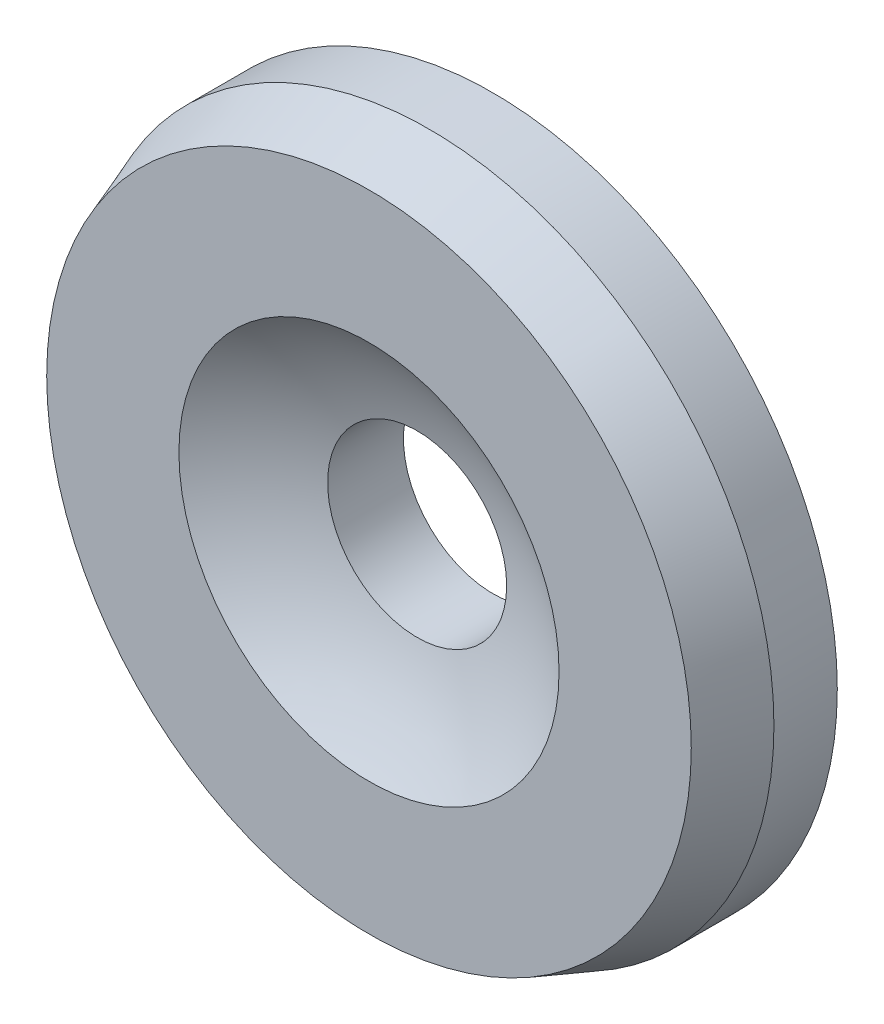
from build123d import *


with BuildPart() as part:
    # Sketch1 → Revolve1 (revolve)
    with BuildSketch(Plane(origin=(0, 0, 0), x_dir=(1, 0, 0), z_dir=(0, 1, 0))):
        with BuildLine():
            Line((1.25, -1.55), (1.25, -1.32))
            Line((1.25, -1.32), (0.325, -1.32))
            Line((0.325, -1.32), (0.325, -1.595159512))
            ThreePointArc((0.325, -1.595159512), (0.514974319, -1.66697624), (0.69, -1.77))
            Line((0.69, -1.77), (1.169926548, -1.77))
            Line((1.169926548, -1.77), (1.25, -1.55))
        make_face()
    revolve(axis=Axis((0, 0, 1.32), (0, 0, 1)))


solid = part.part
